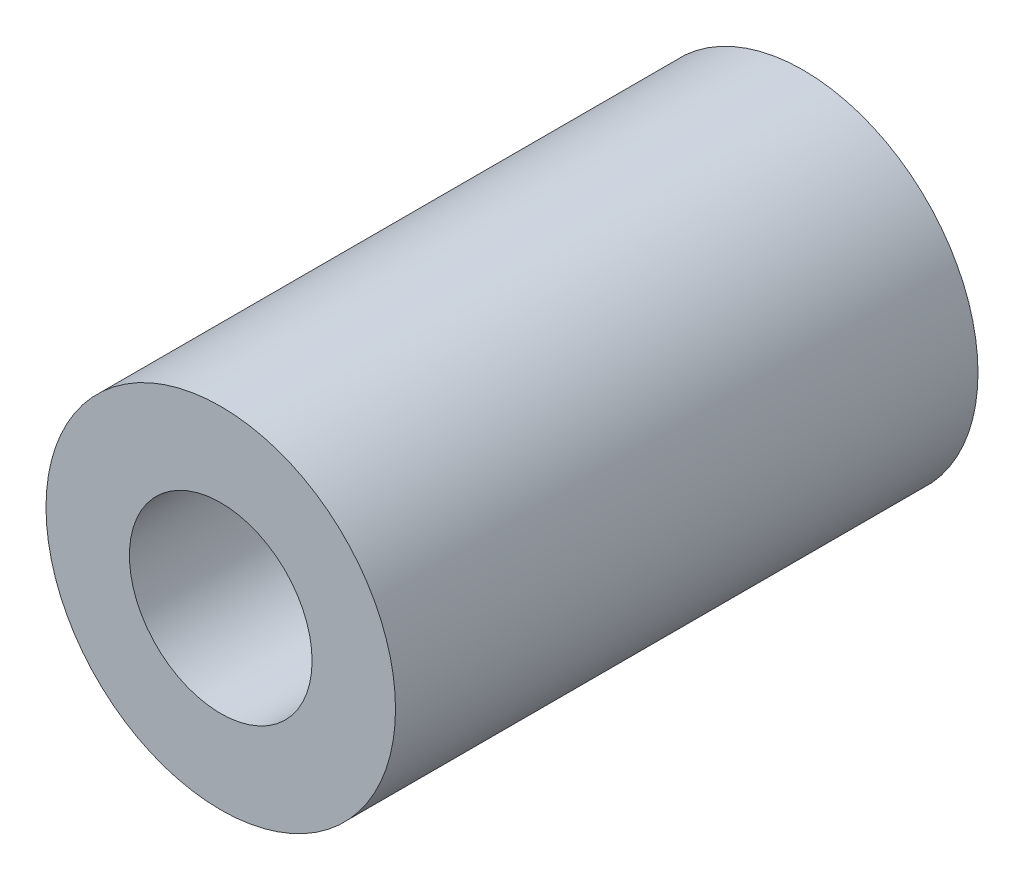
from build123d import *

# Parameters (mm, degrees)
SKETCH1_R           = 4.7625
SKETCH1_R_2         = 2.4892
BOSS_EXTRUDE1_DEPTH = 7.9375


with BuildPart() as part:
    # Sketch1 → Boss-Extrude1 (new body, symmetric)
    with BuildSketch(Plane.XY):
        Circle(SKETCH1_R)
        Circle(SKETCH1_R_2, mode=Mode.SUBTRACT)
    extrude(amount=BOSS_EXTRUDE1_DEPTH, both=True)


solid = part.part
